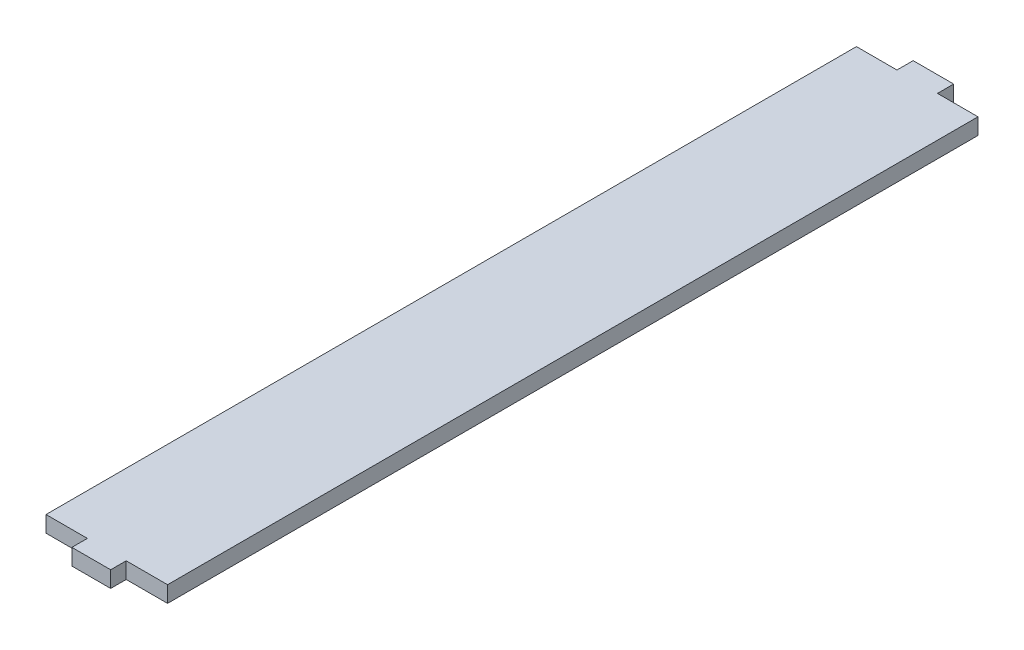
from build123d import *

# Parameters (mm, degrees)
SKETCH1_W           = 9.575779147
SKETCH1_H           = 7.660623318
SKETCH1_W_2         = 30
SKETCH1_H_2         = 200
SKETCH1_W_3         = 10
SKETCH1_H_3         = 8
BOSS_EXTRUDE1_DEPTH = 4


with BuildPart() as part:
    # Sketch1 → Boss-Extrude1 (new body)
    with BuildSketch(Plane(origin=(0, 0, 0), x_dir=(1, 0, 0), z_dir=(0, 1, 0))):
        with Locations((79.848188069, -31.56250034)):
            Rectangle(SKETCH1_W, SKETCH1_H)
        with Locations((79.848188068, 68.43749966)):
            Rectangle(SKETCH1_W_2, SKETCH1_H_2)
        with Locations((79.848188068, 168.43749966)):
            Rectangle(SKETCH1_W_3, SKETCH1_H_3)
    extrude(amount=BOSS_EXTRUDE1_DEPTH)


solid = part.part
